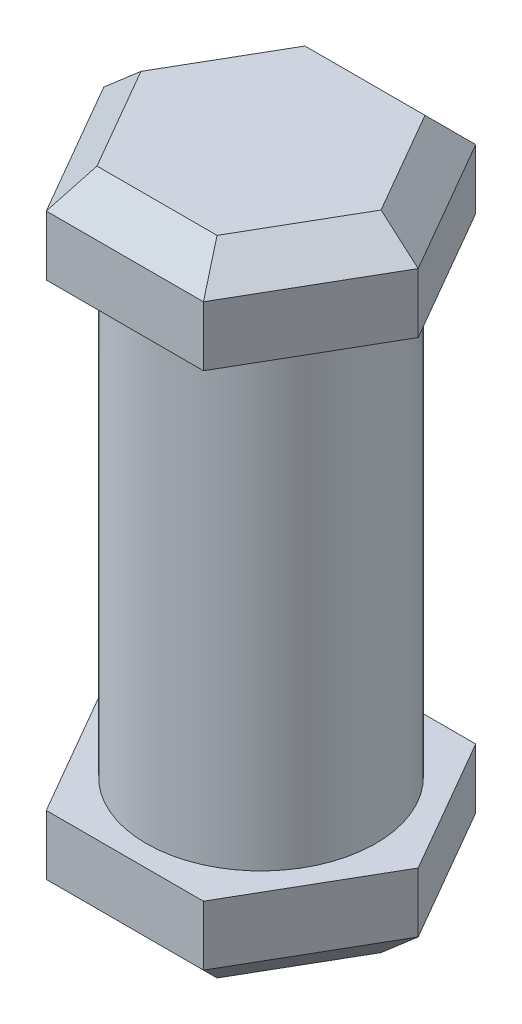
from build123d import *

# Parameters (mm, degrees)
SKETCH1_R           = 2.5
BOSS_EXTRUDE1_DEPTH = 10
BOSS_EXTRUDE2_DEPTH = 2
BOSS_EXTRUDE3_DEPTH = 2
CHAMFER1_SIZE       = 0.7


with BuildPart() as part:
    # Sketch1 → Boss-Extrude1 (new body)
    with BuildSketch(Plane(origin=(0, 0, 0), x_dir=(1, 0, 0), z_dir=(0, 1, 0))):
        Circle(SKETCH1_R)
    extrude(amount=BOSS_EXTRUDE1_DEPTH)

    # Sketch3 → Boss-Extrude2 (add)
    with BuildSketch(Plane.XZ):
        Polygon((3.421887709, 0), (1.710943854, 2.963441685), (-1.710943854, 2.963441685), (-3.421887709, 0), (-1.710943854, -2.963441685), (1.710943854, -2.963441685), align=None)
    extrude(amount=BOSS_EXTRUDE2_DEPTH)

    # Sketch2 → Boss-Extrude3 (add)
    with BuildSketch(Plane(origin=(0, 10, 0), x_dir=(1, 0, 0), z_dir=(0, 1, 0))):
        Polygon((3.421887709, 0), (1.710943854, 2.963441685), (-1.710943854, 2.963441685), (-3.421887709, 0), (-1.710943854, -2.963441685), (1.710943854, -2.963441685), align=None)
    extrude(amount=BOSS_EXTRUDE3_DEPTH)

    # Chamfer1
    chamfer1_edges = [part.edges().sort_by_distance(p)[0] for p in [
        (0, 12, -2.963441685),
        (-2.566415782, 12, -1.481720842),
        (-2.566415782, 12, 1.481720842),
        (0, 12, 2.963441685),
        (2.566415782, 12, 1.481720842),
        (2.566415782, 12, -1.481720842),
        (2.566415782, -2, -1.481720842),
        (2.566415782, -2, 1.481720842),
        (0, -2, 2.963441685),
        (-2.566415782, -2, 1.481720842),
        (-2.566415782, -2, -1.481720842),
        (0, -2, -2.963441685),
    ]]
    chamfer(chamfer1_edges, length=CHAMFER1_SIZE)


solid = part.part
